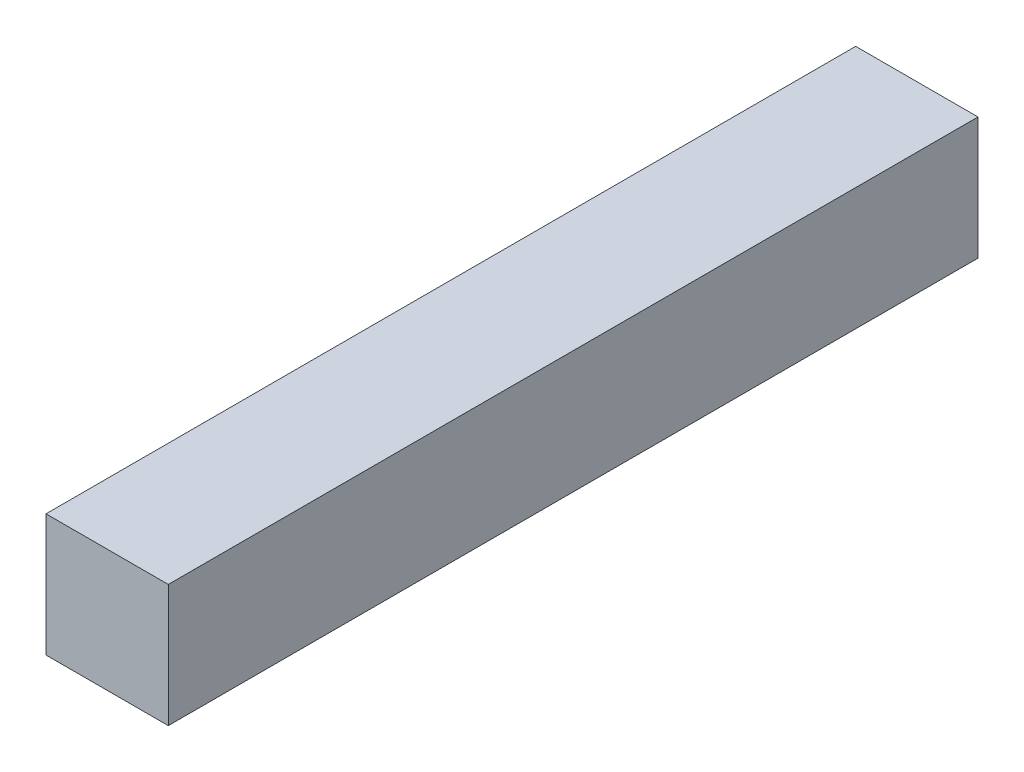
from build123d import *

# Parameters (mm, degrees)
ESQUISSE1_W        = 10
ESQUISSE1_H        = 10
BOSS_EXTRU_1_DEPTH = 66.2


with BuildPart() as part:
    # Esquisse1 → Boss.-Extru.1 (new body)
    with BuildSketch(Plane.XY):
        Rectangle(ESQUISSE1_W, ESQUISSE1_H)
    extrude(amount=BOSS_EXTRU_1_DEPTH)


solid = part.part
